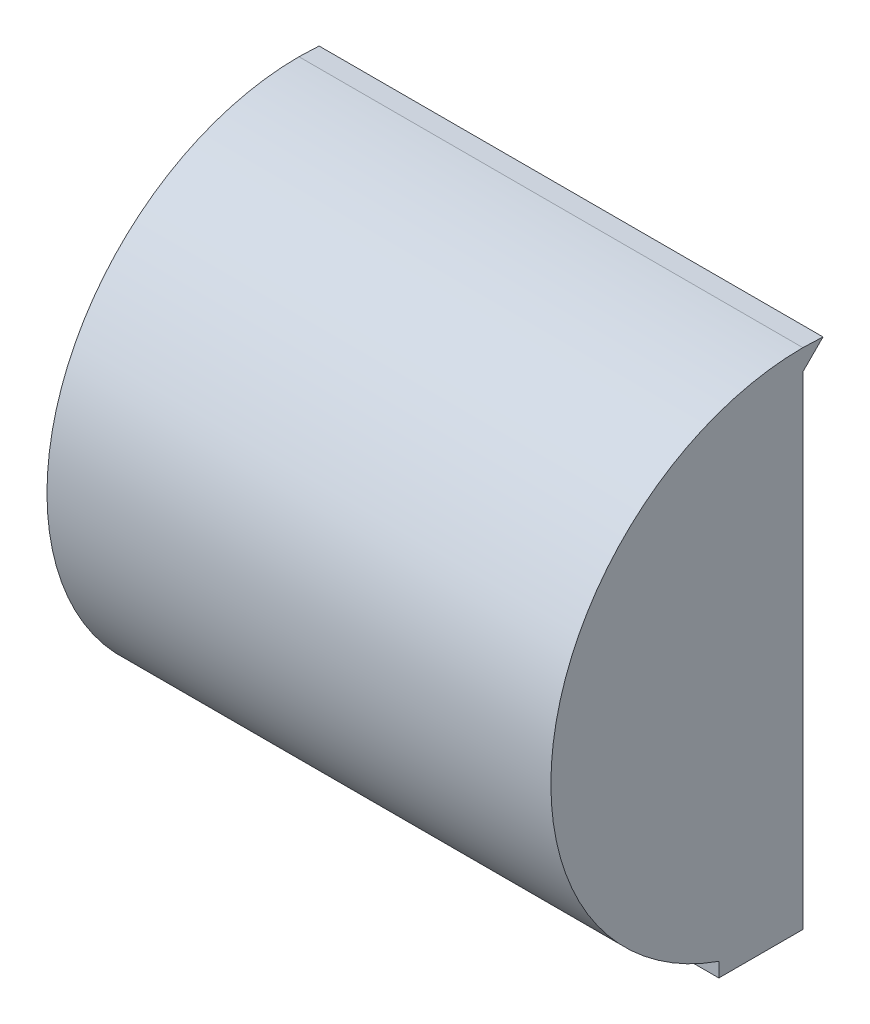
from build123d import *

# Parameters (mm, degrees)
BOSS_EXTRUDE1_DEPTH = 38.1
SHELL1_T            = -3.175
SKETCH7_W           = 76.2
SKETCH7_H           = 3.175
BOSS_EXTRUDE2_DEPTH = 12.7
BOSS_EXTRUDE3_DEPTH = 76.2
CUT_EXTRUDE3_REACH  = 78.2
SKETCH10_R          = 2.0828
CUT_EXTRUDE4_REACH  = 81.375
CUT_EXTRUDE4_START  = -3.175
SKETCH11_R          = 3.429


with BuildPart() as part:
    # Sketch2 → Boss-Extrude1 (new body, symmetric)
    with BuildSketch(Plane(origin=(0, 0, 0), x_dir=(0, 0, -1), z_dir=(1, 0, 0))):
        with BuildLine():
            Line((0, 0), (0, 38.1))
            Line((0, 38.1), (0, 76.2))
            ThreePointArc((0, 76.2), (-38.1, 38.1), (0, 0))
        make_face()
    extrude(amount=BOSS_EXTRUDE1_DEPTH, both=True)

    # Shell1
    shell1_openings = [part.faces().sort_by_distance(p)[0] for p in [
        (0, 38.1, 0),
    ]]
    offset(amount=SHELL1_T, openings=shell1_openings)

    # Sketch7 → Boss-Extrude2 (add)
    with BuildSketch(Plane(origin=(0, 0, 0), x_dir=(1, 0, 0), z_dir=(0, 0, -1))):
        with Locations((0, -1.5875)):
            Rectangle(SKETCH7_W, SKETCH7_H)
    extrude(amount=-BOSS_EXTRUDE2_DEPTH)

    # Sketch8 → Boss-Extrude3 (add)
    with BuildSketch(Plane(origin=(38.1, 0, 0), x_dir=(0, 0, -1), z_dir=(1, 0, 0))):
        Polygon((0, 73.025), (0, 76.2), (3.052521174, 76.077521174), align=None)
    extrude(amount=-BOSS_EXTRUDE3_DEPTH)

    # Sketch10 → Cut-Extrude3 (cut, up to next)
    with BuildSketch(Plane.XZ, mode=Mode.PRIVATE) as cut_extrude3_sk1:
        with Locations((19.05, 6.35)):
            Circle(SKETCH10_R)
    cut_extrude3_tool1 = extrude(cut_extrude3_sk1.sketch, amount=-CUT_EXTRUDE3_REACH, mode=Mode.PRIVATE) & part.part
    add(cut_extrude3_tool1.solids().sort_by_distance((19.05, 0, 6.35))[0], mode=Mode.SUBTRACT)
    # Sketch10 → Cut-Extrude3 (cut, up to next)
    with BuildSketch(Plane.XZ, mode=Mode.PRIVATE) as cut_extrude3_sk2:
        with Locations((-19.05, 6.35)):
            Circle(SKETCH10_R)
    cut_extrude3_tool2 = extrude(cut_extrude3_sk2.sketch, amount=-CUT_EXTRUDE3_REACH, mode=Mode.PRIVATE) & part.part
    add(cut_extrude3_tool2.solids().sort_by_distance((-19.05, 0, 6.35))[0], mode=Mode.SUBTRACT)

    # Sketch11 → Cut-Extrude4 (cut, up to next)
    with BuildSketch(Plane.XZ.offset(CUT_EXTRUDE4_START), mode=Mode.PRIVATE) as cut_extrude4_sk1:
        with Locations((19.05, 6.35)):
            Circle(SKETCH11_R)
    cut_extrude4_tool1 = extrude(cut_extrude4_sk1.sketch, amount=-CUT_EXTRUDE4_REACH, mode=Mode.PRIVATE) & part.part
    add(cut_extrude4_tool1.solids().sort_by_distance((19.05, 3.175, 6.35))[0], mode=Mode.SUBTRACT)
    # Sketch11 → Cut-Extrude4 (cut, up to next)
    with BuildSketch(Plane.XZ.offset(CUT_EXTRUDE4_START), mode=Mode.PRIVATE) as cut_extrude4_sk2:
        with Locations((-19.05, 6.35)):
            Circle(SKETCH11_R)
    cut_extrude4_tool2 = extrude(cut_extrude4_sk2.sketch, amount=-CUT_EXTRUDE4_REACH, mode=Mode.PRIVATE) & part.part
    add(cut_extrude4_tool2.solids().sort_by_distance((-19.05, 3.175, 6.35))[0], mode=Mode.SUBTRACT)


solid = part.part
